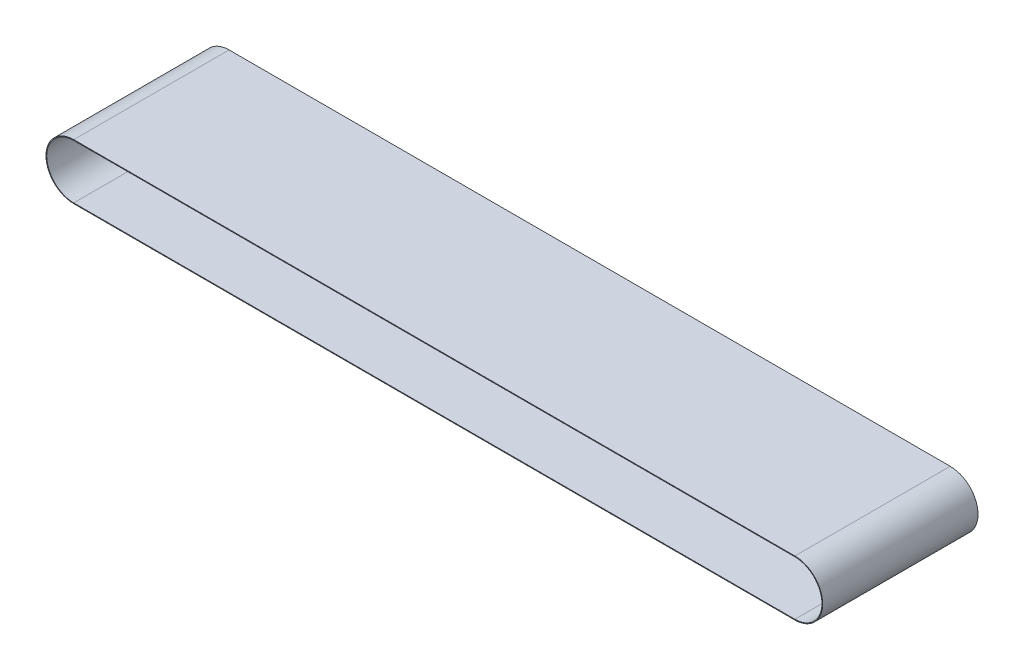
from build123d import *

# Parameters (mm, degrees)
BOSS_EXTRUDE1_DEPTH = 110


with BuildPart() as part:
    # Sketch1 → Boss-Extrude1 (new body)
    with BuildSketch(Plane.XY):
        with BuildLine():
            Line((-255.3, 19.65), (255.3, 19.65))
            ThreePointArc((255.3, 19.65), (274.95, 0), (255.3, -19.65))
            Line((255.3, -19.65), (-255.3, -19.65))
            ThreePointArc((-255.3, -19.65), (-274.95, 0), (-255.3, 19.65))
        make_face()
        with BuildLine():
            Line((-255.3, 19.15), (255.3, 19.15))
            ThreePointArc((255.3, 19.15), (274.45, 0), (255.3, -19.15))
            Line((255.3, -19.15), (-255.3, -19.15))
            ThreePointArc((-255.3, -19.15), (-274.45, 0), (-255.3, 19.15))
        make_face(mode=Mode.SUBTRACT)
    extrude(amount=BOSS_EXTRUDE1_DEPTH)


solid = part.part
